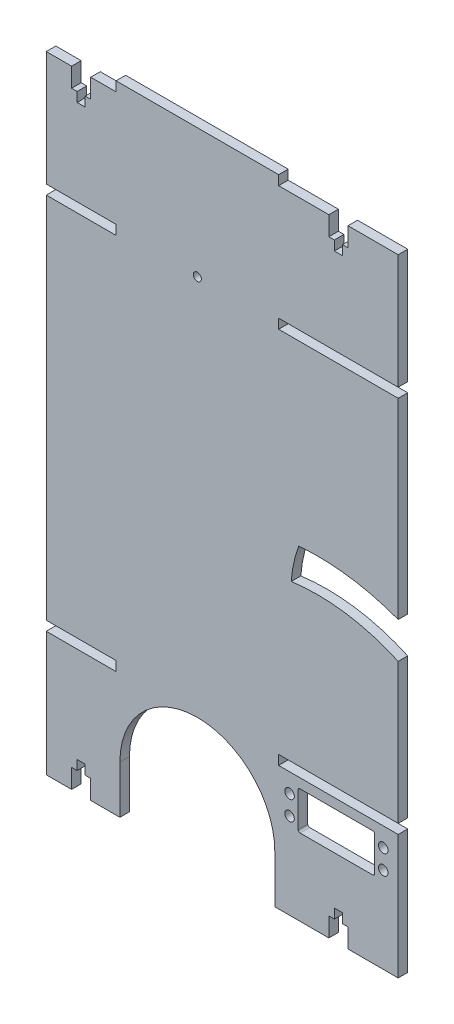
from build123d import *

# Parameters (mm, degrees)
SKETCH2_W           = 184
SKETCH2_H           = 332.5
BOSS_EXTRUDE1_DEPTH = 5
SKETCH3_W           = 36.5
SKETCH3_H           = 5
SKETCH3_W_2         = 62.5
CUT_EXTRUDE1_DEPTH  = 5
CUT_EXTRUDE2_DEPTH  = 10
SKETCH5_R           = 2.1
CUT_EXTRUDE3_DEPTH  = 10
SKETCH6_R           = 2.5
CUT_EXTRUDE4_DEPTH  = 20
CUT_EXTRUDE6_DEPTH  = 6


with BuildPart() as part:
    # Sketch2 → Boss-Extrude1 (new body)
    with BuildSketch(Plane.XY):
        Rectangle(SKETCH2_W, SKETCH2_H)
    extrude(amount=BOSS_EXTRUDE1_DEPTH)

    # Sketch3 → Cut-Extrude1 (cut)
    with BuildSketch(Plane.XY.offset(5)):
        with Locations((-73.75, -98.75)):
            Rectangle(SKETCH3_W, SKETCH3_H)
        with Locations((60.75, -98.75)):
            Rectangle(SKETCH3_W_2, SKETCH3_H)
        with Locations((-73.75, 163.75)):
            Rectangle(SKETCH3_W, SKETCH3_H)
        with Locations((60.75, 163.75)):
            Rectangle(SKETCH3_W_2, SKETCH3_H)
        with Locations((60.75, 98.75)):
            Rectangle(SKETCH3_W_2, SKETCH3_H)
        with BuildLine():
            Line((27.5, -141.25), (27.5, -166.25))
            Line((27.5, -166.25), (-53.5, -166.25))
            Line((-53.5, -166.25), (-53.5, -141.25))
            ThreePointArc((-53.5, -141.25), (-13, -100.75), (27.5, -141.25))
        make_face()
        with Locations((-73.75, 98.75)):
            Rectangle(SKETCH3_W, SKETCH3_H)
    extrude(amount=-CUT_EXTRUDE1_DEPTH, mode=Mode.SUBTRACT)

    # Sketch4 → Cut-Extrude2 (cut)
    with BuildSketch(Plane.XY.offset(5)):
        Polygon((55.75, 161.25), (55.75, 151.25), (58.65, 151.25), (58.65, 146.25), (62.85, 146.25), (62.85, 151.25), (65.75, 151.25), (65.75, 161.25), align=None)
        Polygon((-78.75, 161.25), (-78.75, 151.25), (-75.85, 151.25), (-75.85, 146.25), (-71.65, 146.25), (-71.65, 151.25), (-68.75, 151.25), (-68.75, 161.25), align=None)
        Polygon((65.75, -166.25), (65.75, -156.25), (62.85, -156.25), (62.85, -151.25), (58.65, -151.25), (58.65, -156.25), (55.75, -156.25), (55.75, -166.25), align=None)
        Polygon((-68.75, -166.25), (-68.75, -156.25), (-71.65, -156.25), (-71.65, -151.25), (-75.85, -151.25), (-75.85, -156.25), (-78.75, -156.25), (-78.75, -166.25), align=None)
    extrude(amount=-CUT_EXTRUDE2_DEPTH, mode=Mode.SUBTRACT)

    # Sketch5 → Cut-Extrude3 (cut)
    with BuildSketch(Plane.XY.offset(5)):
        with Locations((-13, 98.75)):
            Circle(SKETCH5_R)
    extrude(amount=-CUT_EXTRUDE3_DEPTH, mode=Mode.SUBTRACT)

    # Sketch6 → Cut-Extrude4 (cut)
    with BuildSketch(Plane(origin=(0, 0, 0), x_dir=(-1, 0, 0), z_dir=(0, 0, -1))):
        with Locations((-35.2, -111.17)):
            Circle(SKETCH6_R)
        with Locations((-35.2, -121.33)):
            Circle(SKETCH6_R)
        with Locations((-84.2, -111.17)):
            Circle(SKETCH6_R)
        with Locations((-84.2, -121.33)):
            Circle(SKETCH6_R)
        with BuildLine():
            Line((-78.2, -106.25), (-41.2, -106.25))
            Line((-41.2, -106.25), (-40.7, -106.25))
            ThreePointArc((-40.7, -106.25), (-39.992893219, -106.542893219), (-39.7, -107.25))
            Line((-39.7, -107.25), (-39.7, -125.25))
            ThreePointArc((-39.7, -125.25), (-39.992893219, -125.957106781), (-40.7, -126.25))
            Line((-40.7, -126.25), (-78.7, -126.25))
            ThreePointArc((-78.7, -126.25), (-79.407106781, -125.957106781), (-79.7, -125.25))
            Line((-79.7, -125.25), (-79.7, -107.25))
            ThreePointArc((-79.7, -107.25), (-79.407106781, -106.542893219), (-78.7, -106.25))
            Line((-78.7, -106.25), (-78.2, -106.25))
        make_face()
    extrude(amount=-CUT_EXTRUDE4_DEPTH, mode=Mode.SUBTRACT)

    # Sketch7 → Cut-Extrude6 (cut, through all)
    with BuildSketch(Plane.XY.offset(5)):
        with BuildLine():
            Line((92.018319465, -3.95948465), (92, -22.885338591))
            ThreePointArc((92, -22.885338591), (64.618518363, -14.841480585), (36.080546525, -14.658856257))
            ThreePointArc((36.080546525, -14.658856257), (37.397553955, -5.515336457), (39.976105832, 3.355375641))
            ThreePointArc((39.976105832, 3.355375641), (66.402572717, 2.581915177), (92.018319465, -3.95948465))
        make_face()
    extrude(amount=-CUT_EXTRUDE6_DEPTH, mode=Mode.SUBTRACT)


solid = part.part
